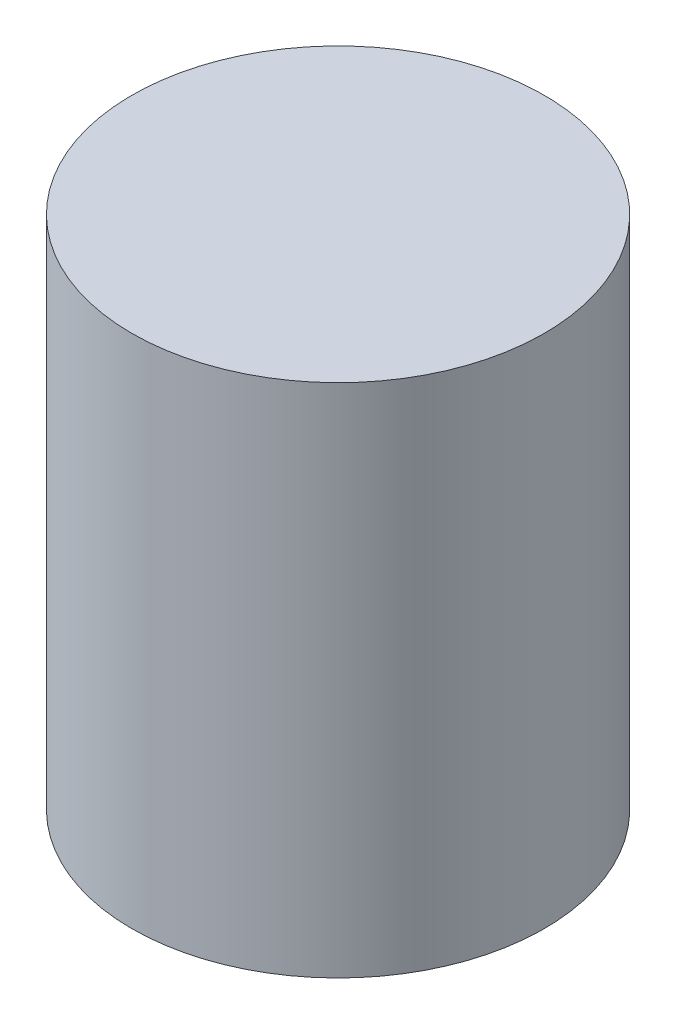
from build123d import *

# Parameters (mm, degrees)
SKETCH1_R           = 20
BOSS_EXTRUDE1_DEPTH = 50


with BuildPart() as part:
    # Sketch1 → Boss-Extrude1 (new body)
    with BuildSketch(Plane(origin=(0, 0, 0), x_dir=(1, 0, 0), z_dir=(0, 1, 0))):
        Circle(SKETCH1_R)
    extrude(amount=BOSS_EXTRUDE1_DEPTH)


solid = part.part
